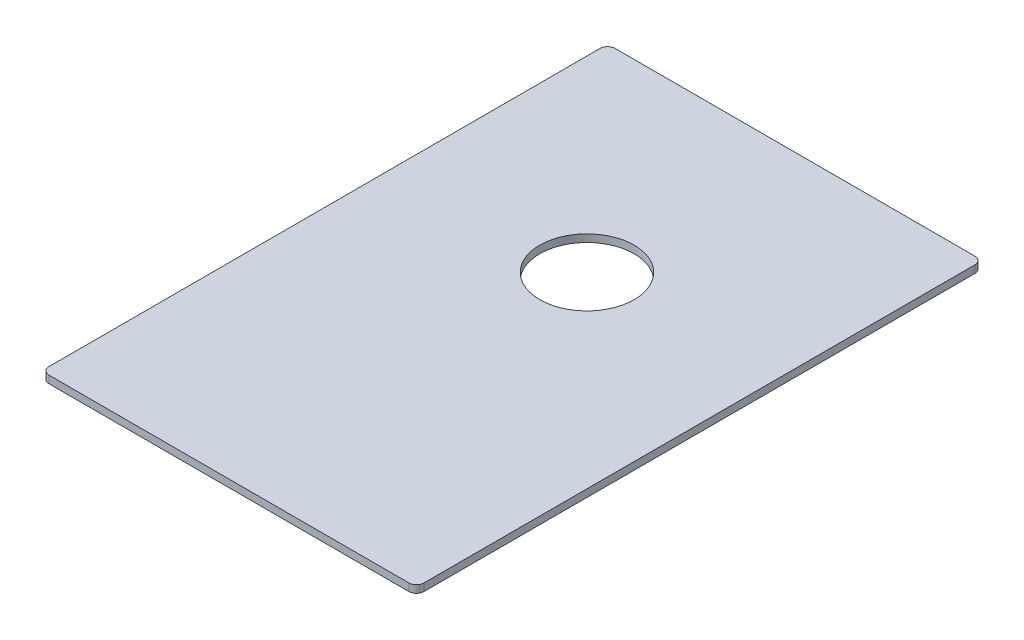
from build123d import *

# Parameters (mm, degrees)
SKETCH1_W           = 500
SKETCH1_H           = 755
BOSS_EXTRUDE1_DEPTH = 10
SKETCH3_R           = 63
CUT_EXTRUDE10_DEPTH = 11
FILLET1_R           = 10


with BuildPart() as part:
    # Sketch1 → Boss-Extrude1 (new body)
    with BuildSketch(Plane(origin=(0, 0, 0), x_dir=(1, 0, 0), z_dir=(0, 1, 0))):
        Rectangle(SKETCH1_W, SKETCH1_H)
    extrude(amount=BOSS_EXTRUDE1_DEPTH)

    # Sketch3 → Cut-Extrude10 (cut, through all)
    with BuildSketch(Plane(origin=(0, 0, 0), x_dir=(1, 0, 0), z_dir=(0, 1, 0))):
        with Locations((0, 100)):
            Circle(SKETCH3_R)
    extrude(amount=CUT_EXTRUDE10_DEPTH, mode=Mode.SUBTRACT)

    # Fillet1
    fillet1_edges = [part.edges().sort_by_distance(p)[0] for p in [
        (-250, 5, 377.5),
        (-250, 5, -377.5),
        (250, 5, -377.5),
        (250, 5, 377.5),
    ]]
    fillet(fillet1_edges, radius=FILLET1_R)


solid = part.part
